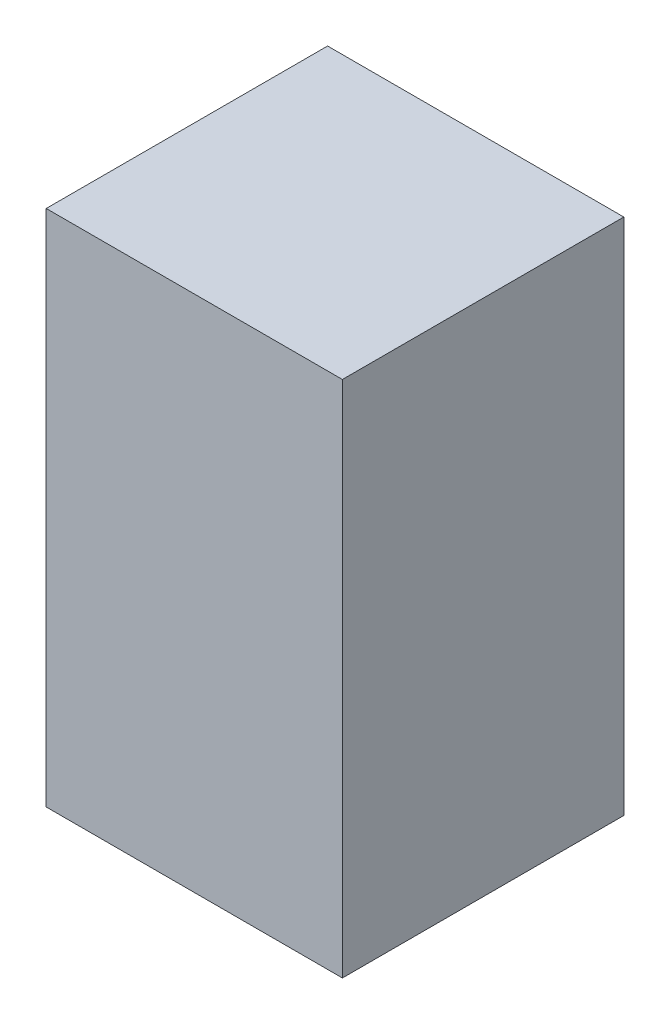
from build123d import *

# Parameters (mm, degrees)
SKETCH1_W           = 25.4
SKETCH1_H           = 44.45
BOSS_EXTRUDE1_DEPTH = 24.13


with BuildPart() as part:
    # Sketch1 → Boss-Extrude1 (new body)
    with BuildSketch(Plane.XY):
        with Locations((12.7, 22.225)):
            Rectangle(SKETCH1_W, SKETCH1_H)
    extrude(amount=BOSS_EXTRUDE1_DEPTH)


solid = part.part
